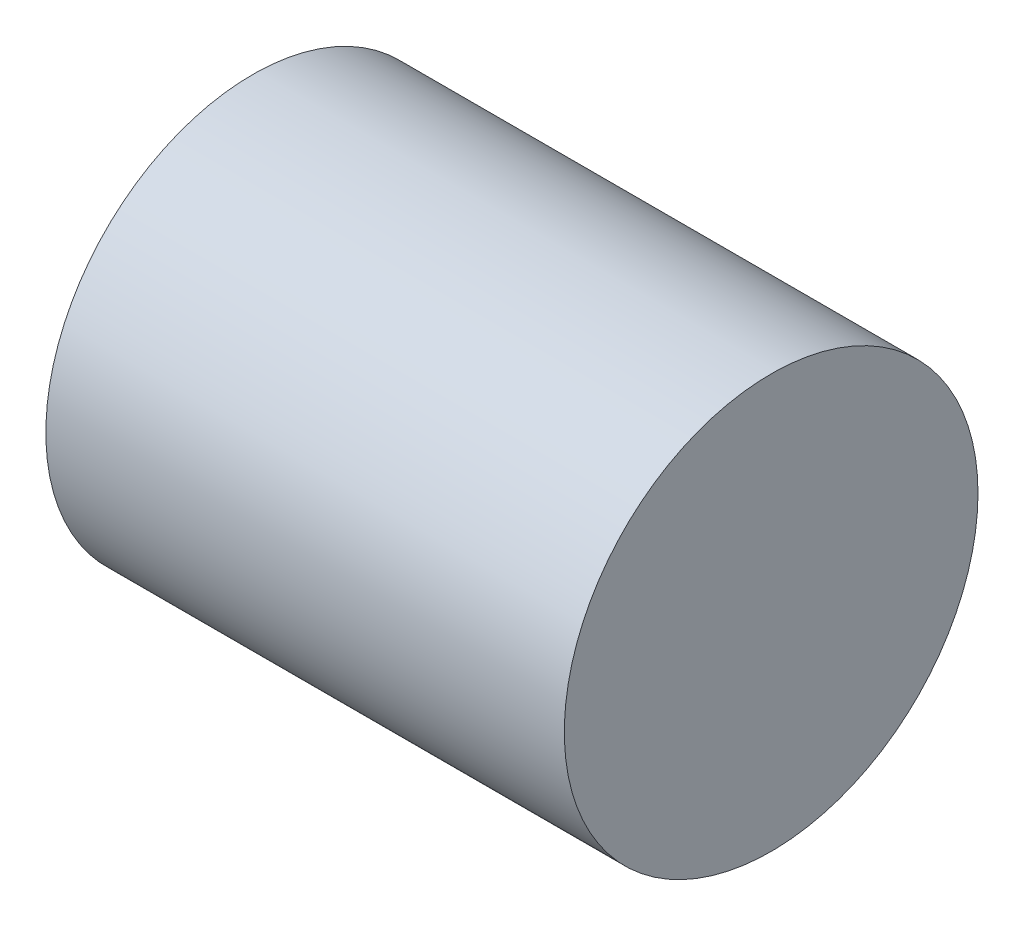
from build123d import *

# Parameters (mm, degrees)
SKETCH1_R           = 0.79788456
BOSS_EXTRUDE1_DEPTH = 2


with BuildPart() as part:
    # Sketch1 → Boss-Extrude1 (new body)
    with BuildSketch(Plane(origin=(0, 0, 0), x_dir=(0, 0, -1), z_dir=(1, 0, 0))):
        Circle(SKETCH1_R)
    extrude(amount=BOSS_EXTRUDE1_DEPTH)


solid = part.part
